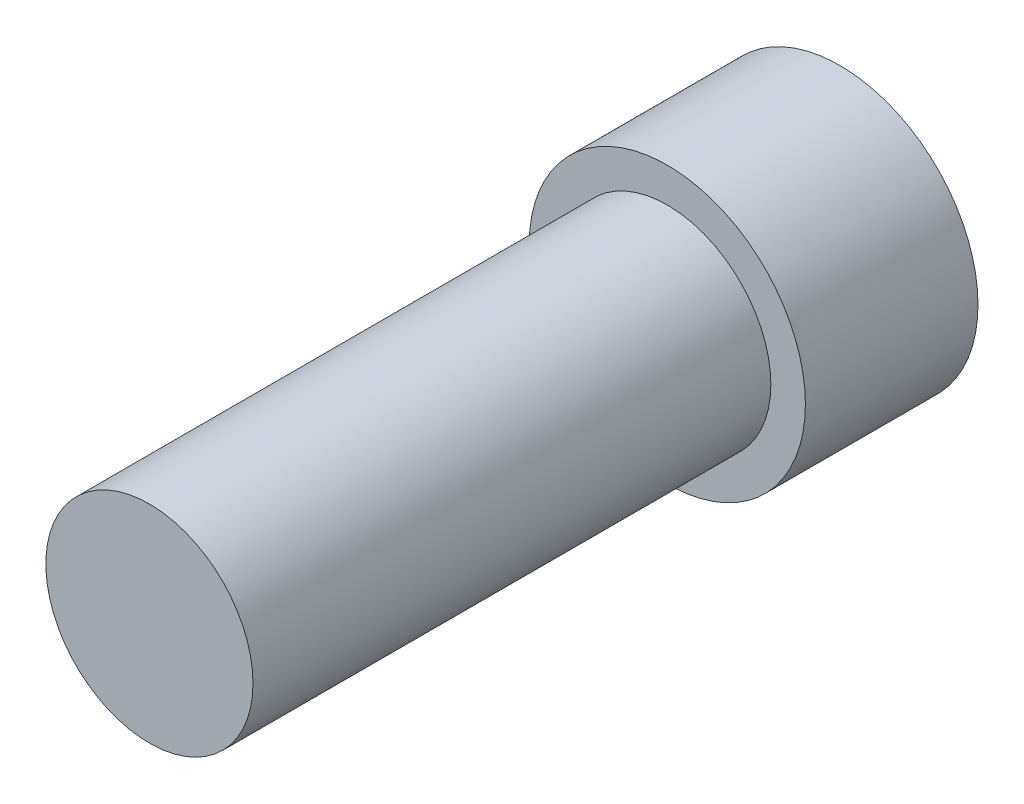
from build123d import *

# Parameters (mm, degrees)
SKETCH1_R           = 4
BOSS_EXTRUDE1_DEPTH = 5
SKETCH2_R           = 3
BOSS_EXTRUDE2_DEPTH = 15
CUT_EXTRUDE1_DEPTH  = 3


with BuildPart() as part:
    # Sketch1 → Boss-Extrude1 (new body)
    with BuildSketch(Plane.XY):
        Circle(SKETCH1_R)
    extrude(amount=BOSS_EXTRUDE1_DEPTH)

    # Sketch2 → Boss-Extrude2 (add)
    with BuildSketch(Plane.XY.offset(5)):
        Circle(SKETCH2_R)
    extrude(amount=BOSS_EXTRUDE2_DEPTH)

    # Sketch3 → Cut-Extrude1 (cut)
    with BuildSketch(Plane(origin=(0, 0, 0), x_dir=(-1, 0, 0), z_dir=(0, 0, -1))):
        Polygon((0.294791558, -2.782244545), (2.556890234, -1.135825295), (2.262098677, 1.64641925), (-0.294791558, 2.782244545), (-2.556890234, 1.135825295), (-2.262098677, -1.64641925), align=None)
    extrude(amount=-CUT_EXTRUDE1_DEPTH, mode=Mode.SUBTRACT)


solid = part.part
